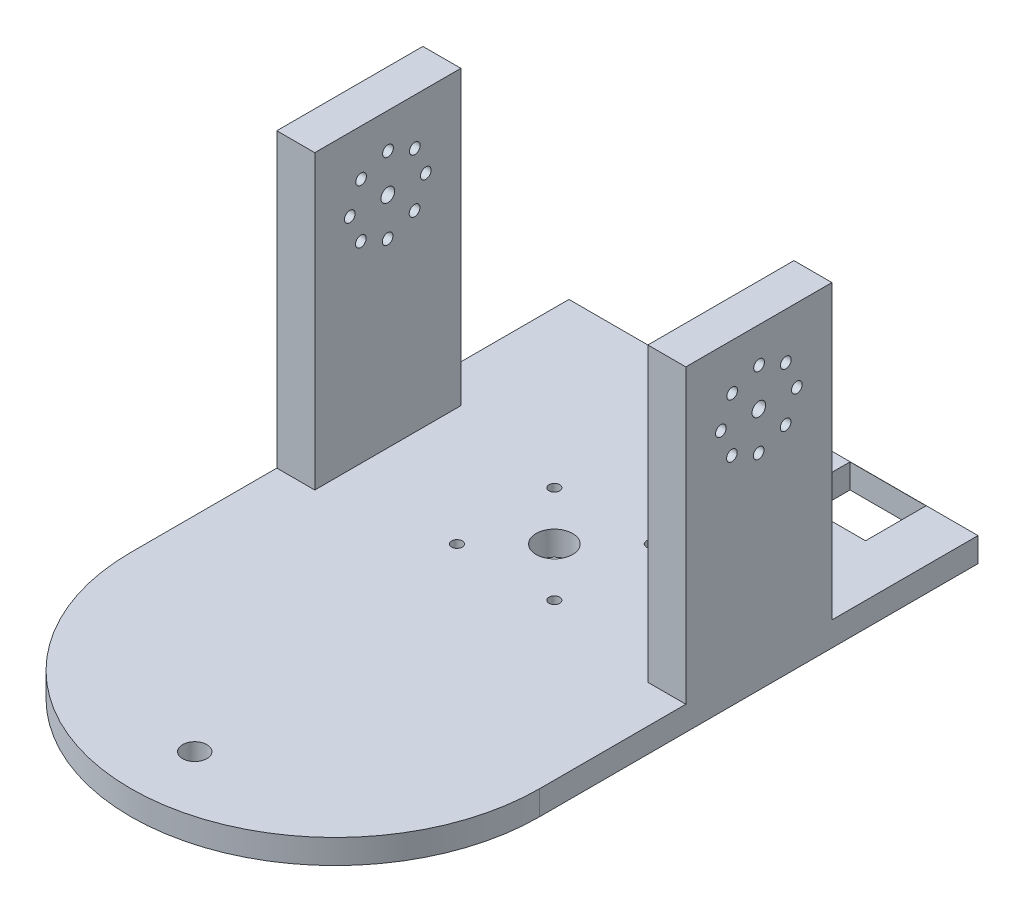
from build123d import *

# Parameters (mm, degrees)
SKETCH1_R                    = 4.572
SKETCH1_R_2                  = 1.397
SKETCH1_R_3                  = 3.175
BOSS_EXTRUDE1_DEPTH          = 6.35
F_3_8_0_375_DIAMETER_SLOT1_D = 9.525
SKETCH6_W                    = 9.906
SKETCH6_H                    = 38.1
BOSS_EXTRUDE2_DEPTH          = 76.2
SKETCH7_R                    = 1.397
SKETCH7_R_2                  = 1.7859375
CUT_EXTRUDE1_DEPTH           = 107.68
CUT_EXTRUDE2_DEPTH           = 10.16


with BuildPart() as part:
    # Sketch1 → Boss-Extrude1 (new body)
    with BuildSketch(Plane(origin=(0, 0, 0), x_dir=(1, 0, 0), z_dir=(0, 1, 0))):
        with BuildLine():
            Line((-53.34, 57.15), (53.34, 57.15))
            Line((53.34, 57.15), (53.34, -57.15))
            ThreePointArc((53.34, -57.15), (0, -110.49), (-53.34, -57.15))
            Line((-53.34, -57.15), (-53.34, 57.15))
        make_face()
        Circle(SKETCH1_R, mode=Mode.SUBTRACT)
        with Locations((-12.7, -12.7)):
            Circle(SKETCH1_R_2, mode=Mode.SUBTRACT)
        with Locations((-12.7, 12.7)):
            Circle(SKETCH1_R_2, mode=Mode.SUBTRACT)
        with Locations((12.7, 12.7)):
            Circle(SKETCH1_R_2, mode=Mode.SUBTRACT)
        with Locations((12.7, -12.7)):
            Circle(SKETCH1_R_2, mode=Mode.SUBTRACT)
        with Locations((0, -93.791156658)):
            Circle(SKETCH1_R_3, mode=Mode.SUBTRACT)
    extrude(amount=BOSS_EXTRUDE1_DEPTH)

    # 3/8 (0.375) Diameter Slot1 (through all)
    with Locations(Plane(origin=(0, 6.35, 0), x_dir=(1, 0, 0), z_dir=(0, 1, 0))):
        with Locations((0, 0)):
            Hole(F_3_8_0_375_DIAMETER_SLOT1_D / 2)

    # Sketch6 → Boss-Extrude2 (add)
    with BuildSketch(Plane(origin=(0, 6.35, 0), x_dir=(1, 0, 0), z_dir=(0, 1, 0))):
        with Locations((-48.387, 0)):
            Rectangle(SKETCH6_W, SKETCH6_H)
        with Locations((48.387, 0)):
            Rectangle(SKETCH6_W, SKETCH6_H)
    extrude(amount=BOSS_EXTRUDE2_DEPTH)

    # Sketch7 → Cut-Extrude1 (cut, through all)
    with BuildSketch(Plane.ZY.offset(53.34)):
        with Locations((-9.906, 63.455207007)):
            Circle(SKETCH7_R)
        with Locations((0, 63.5)):
            Circle(SKETCH7_R_2)
        with Locations((-7.036273203, 70.472926346)):
            Circle(SKETCH7_R)
        with Locations((-0.044792993, 73.406)):
            Circle(SKETCH7_R)
        with Locations((6.972926346, 70.536273203)):
            Circle(SKETCH7_R)
        with Locations((9.906, 63.544792993)):
            Circle(SKETCH7_R)
        with Locations((7.036273203, 56.527073654)):
            Circle(SKETCH7_R)
        with Locations((0.044792993, 53.594)):
            Circle(SKETCH7_R)
        with Locations((-6.972926346, 56.463726797)):
            Circle(SKETCH7_R)
    extrude(amount=-CUT_EXTRUDE1_DEPTH, mode=Mode.SUBTRACT)

    # Sketch8 → Cut-Extrude2 (cut)
    with BuildSketch(Plane(origin=(0, 6.35, 0), x_dir=(1, 0, 0), z_dir=(0, 1, 0))):
        Polygon((29.925449695, 49.207255953), (20.005730679, 57.103391791), (20.005730679, 41.311120115), align=None)
        Polygon((29.925449695, 49.207255953), (20.005730679, 41.311120115), (39.84516871, 41.311120115), align=None)
        Polygon((39.84516871, 41.311120115), (39.84516871, 57.103391791), (29.925449695, 49.207255953), align=None)
        Polygon((39.84516871, 57.103391791), (20.005730679, 57.103391791), (29.925449695, 49.207255953), align=None)
    extrude(amount=-CUT_EXTRUDE2_DEPTH, mode=Mode.SUBTRACT)


solid = part.part
